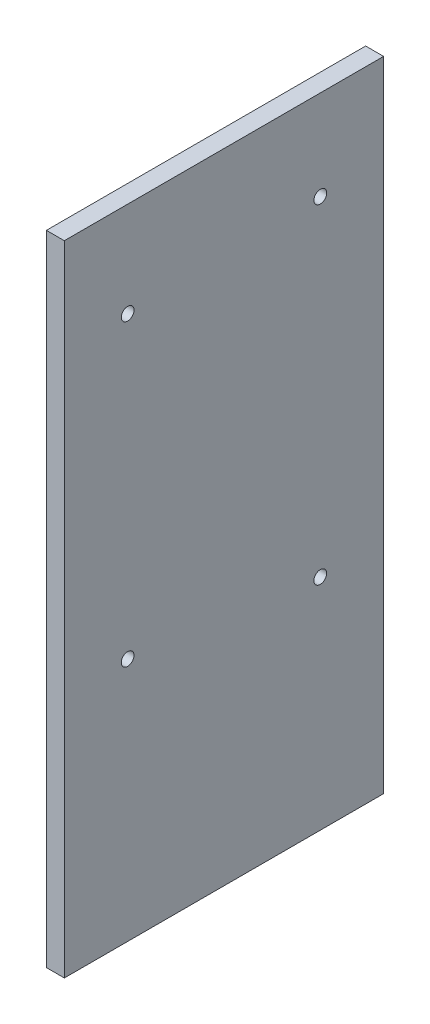
from build123d import *

# Parameters (mm, degrees)
SKETCH1_W           = 80
SKETCH1_H           = 160
BOSS_EXTRUDE1_DEPTH = 4.5
SKETCH2_R           = 1.6
CUT_EXTRUDE1_DEPTH  = 4.5


with BuildPart() as part:
    # Sketch1 → Boss-Extrude1 (new body)
    with BuildSketch(Plane(origin=(0, 0, 0), x_dir=(0, 0, -1), z_dir=(1, 0, 0))):
        Rectangle(SKETCH1_W, SKETCH1_H)
    extrude(amount=BOSS_EXTRUDE1_DEPTH)

    # Sketch2 → Cut-Extrude1 (cut)
    with BuildSketch(Plane.ZY):
        with Locations((-24.14, 57.5)):
            Circle(SKETCH2_R)
        with Locations((24.14, 56.23)):
            Circle(SKETCH2_R)
        with Locations((24.14, -18.7)):
            Circle(SKETCH2_R)
        with Locations((-24.12, -25.05)):
            Circle(SKETCH2_R)
    extrude(amount=-CUT_EXTRUDE1_DEPTH, mode=Mode.SUBTRACT)


solid = part.part
